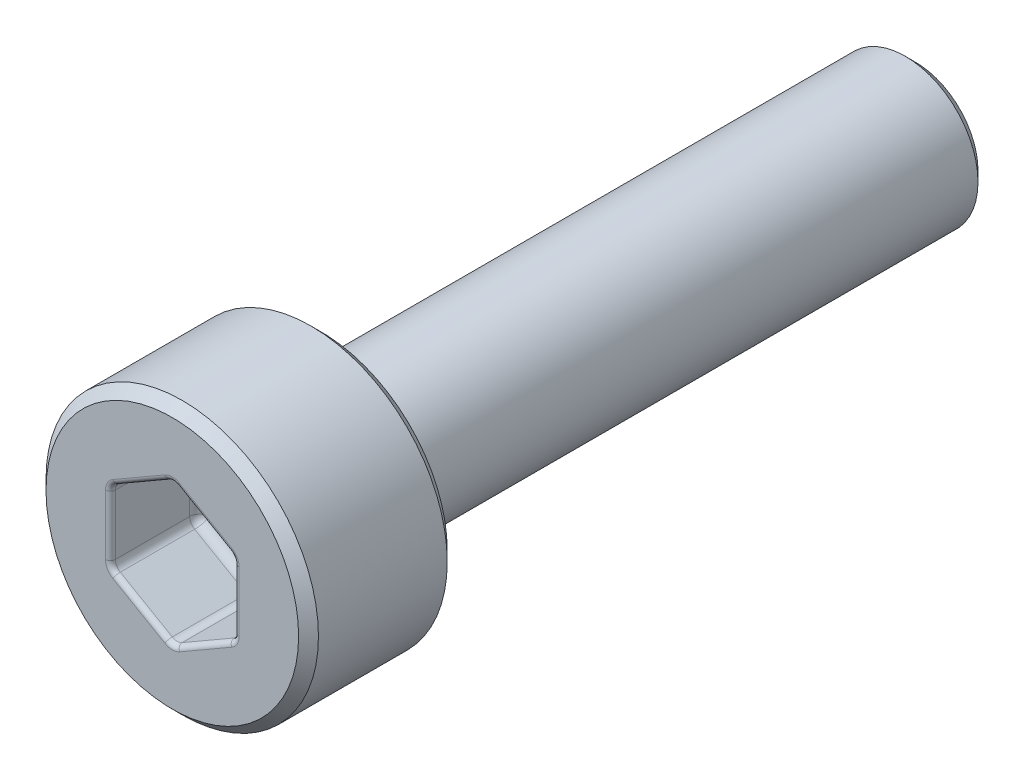
from build123d import *

# Parameters (mm, degrees)
SCHNITT_LINEAR_AUSTRAGEN1_DEPTH = 1.8
FASE1_SIZE                      = 0.2
VERRUNDUNG1_R                   = 0.2
VERRUNDUNG2_R                   = 0.1


with BuildPart() as part:
    # Skizze1 → Rotation1 (revolve)
    with BuildSketch(Plane(origin=(0, 0, 0), x_dir=(0, 0, -1), z_dir=(1, 0, 0))):
        Polygon((-3, 0), (-3, 2.75), (0, 2.75), (0, 1.465), (12, 1.465), (12, 0), align=None)
    revolve(axis=Axis((0, 0, 21.919879518), (0, 0, -1)))

    # Skizze2 → Schnitt-Linear austragen1 (cut)
    with BuildSketch(Plane.XY.offset(3)):
        Polygon((1.25, -0.721687836), (1.25, 0.721687836), (0, 1.443375673), (-1.25, 0.721687836), (-1.25, -0.721687836), (0, -1.443375673), align=None)
    extrude(amount=-SCHNITT_LINEAR_AUSTRAGEN1_DEPTH, mode=Mode.SUBTRACT)

    # Fase1
    fase1_edges = [part.edges().sort_by_distance(p)[0] for p in [
        (0, -2.75, 3),
        (0, -2.75, 0),
        (0, -1.465, -12),
    ]]
    chamfer(fase1_edges, length=FASE1_SIZE)

    # Verrundung1
    verrundung1_edges = [part.edges().sort_by_distance(p)[0] for p in [
        (-0.625, -1.082531755, 1.2),
        (-1.25, 0, 1.2),
        (-0.625, 1.082531755, 1.2),
        (0.625, 1.082531755, 1.2),
        (1.25, 0, 1.2),
        (0.625, -1.082531755, 1.2),
        (-1.25, -0.721687836, 2.1),
        (0, -1.443375673, 2.1),
        (1.25, -0.721687836, 2.1),
        (1.25, 0.721687836, 2.1),
        (0, 1.443375673, 2.1),
        (-1.25, 0.721687836, 2.1),
        (0, -1.465, 0),
    ]]
    fillet(verrundung1_edges, radius=VERRUNDUNG1_R)

    # Verrundung2
    verrundung2_edges = [part.edges().sort_by_distance(p)[0] for p in [
        (1.223205081, -0.706217783, 3),
        (0.625, -1.082531755, 3),
        (0, -1.412435565, 3),
        (-0.625, -1.082531755, 3),
        (-1.223205081, -0.706217783, 3),
        (-1.25, 0, 3),
        (-1.223205081, 0.706217783, 3),
        (-0.625, 1.082531755, 3),
        (0, 1.412435565, 3),
        (0.625, 1.082531755, 3),
        (1.223205081, 0.706217783, 3),
        (1.25, 0, 3),
    ]]
    fillet(verrundung2_edges, radius=VERRUNDUNG2_R)


solid = part.part
